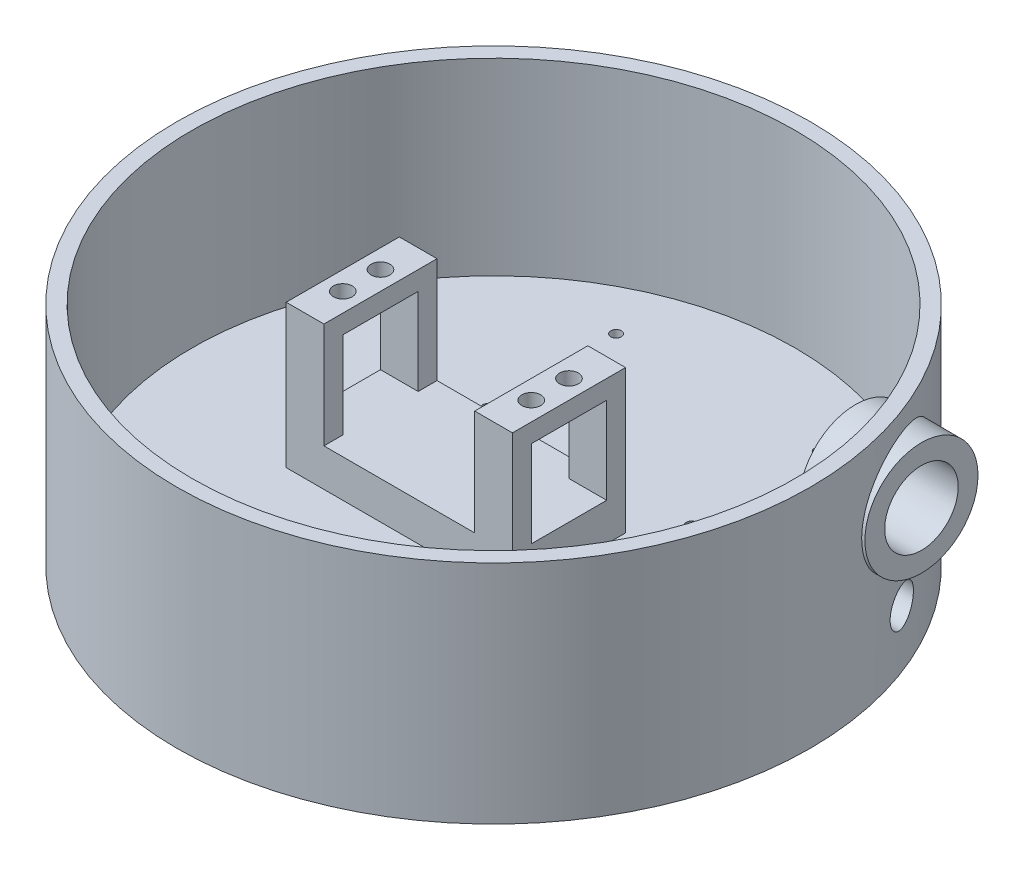
from build123d import *

# Parameters (mm, degrees)
SKETCH1_R                   = 84
BASE_DEPTH                  = 10
SKETCH2_R                   = 84
SKETCH2_R_2                 = 80
WALLS_DEPTH                 = 50
SKETCH3_W                   = 10.006475694
SKETCH3_H                   = 5
MOTOR_MOUNT_1_DEPTH         = 38
SKETCH3_5_W                 = 10
SKETCH3_5_H                 = 5
MOTOR_MOUNT_2_DEPTH         = 38
SKETCH6_W                   = 10.006475694
SKETCH6_H                   = 20
SKETCH6_R                   = 2.5
SKETCH6_W_2                 = 10
MOTOR_SCREW_HOLES_DEPTH     = 5
SKETCH7_R                   = 1.4
PERFBOARD_SCREW_HOLES_DEPTH = 6
BOSS_EXTRUDE1_DEPTH         = 10
SKETCH10_R                  = 9.75
SKETCH10_R_2                = 5
CUT_EXTRUDE1_DEPTH          = 134.086438077
BOSS_EXTRUDE2_START         = 66
SKETCH10_3_R                = 15
SKETCH10_3_R_2              = 9.75
BOSS_EXTRUDE2_DEPTH         = 17.5


with BuildPart() as part:
    # Sketch1 → base (new body)
    with BuildSketch(Plane(origin=(0, 0, 0), x_dir=(1, 0, 0), z_dir=(0, 1, 0))):
        Circle(SKETCH1_R)
    extrude(amount=BASE_DEPTH)

    # Sketch2 → walls (add)
    with BuildSketch(Plane(origin=(0, 10, 0), x_dir=(1, 0, 0), z_dir=(0, 1, 0))):
        Circle(SKETCH2_R)
        Circle(SKETCH2_R_2, mode=Mode.SUBTRACT)
    extrude(amount=WALLS_DEPTH)

    # Sketch3 → motor mount 1 (add)
    with BuildSketch(Plane(origin=(0, 10, 0), x_dir=(1, 0, 0), z_dir=(0, 1, 0))):
        with Locations((15.003237847, -12.5)):
            Rectangle(SKETCH3_W, SKETCH3_H)
        with Locations((15.003237847, 12.5)):
            Rectangle(SKETCH3_W, SKETCH3_H)
    extrude(amount=MOTOR_MOUNT_1_DEPTH)

    # Sketch3_5 → motor mount 2 (add)
    with BuildSketch(Plane(origin=(0, 10, 0), x_dir=(1, 0, 0), z_dir=(0, 1, 0))):
        with Locations((-35, -12.5)):
            Rectangle(SKETCH3_5_W, SKETCH3_5_H)
        with Locations((-35, 12.5)):
            Rectangle(SKETCH3_5_W, SKETCH3_5_H)
    extrude(amount=MOTOR_MOUNT_2_DEPTH)

    # Sketch6 → motor screw holes (add)
    # profile 1 of 2: a face of its own
    with BuildSketch(Plane(origin=(0, 48, 0), x_dir=(1, 0, 0), z_dir=(0, 1, 0))):
        with Locations((15.003237847, 0)):
            Rectangle(SKETCH6_W, SKETCH6_H)
        with Locations((15, 5)):
            Circle(SKETCH6_R, mode=Mode.SUBTRACT)
        with Locations((15, -5)):
            Circle(SKETCH6_R, mode=Mode.SUBTRACT)
    # profile 2 of 2: a face of its own
    with BuildSketch(Plane(origin=(0, 48, 0), x_dir=(1, 0, 0), z_dir=(0, 1, 0))):
        with Locations((-35, 0)):
            Rectangle(SKETCH6_W_2, SKETCH6_H)
        with Locations((-35, 5)):
            Circle(SKETCH6_R, mode=Mode.SUBTRACT)
        with Locations((-35, -5)):
            Circle(SKETCH6_R, mode=Mode.SUBTRACT)
    extrude(amount=-MOTOR_SCREW_HOLES_DEPTH)

    # Sketch7 → perfboard screw holes (cut)
    with BuildSketch(Plane(origin=(0, 10, 0), x_dir=(1, 0, 0), z_dir=(0, 1, 0))):
        with Locations((-27, 59.5)):
            Circle(SKETCH7_R)
        with Locations((-27, 25.5)):
            Circle(SKETCH7_R)
        with Locations((27, 25.5)):
            Circle(SKETCH7_R)
        with Locations((27, 59.5)):
            Circle(SKETCH7_R)
    extrude(amount=-PERFBOARD_SCREW_HOLES_DEPTH, mode=Mode.SUBTRACT)

    # Sketch9 → Boss-Extrude1 (add)
    with BuildSketch(Plane(origin=(0, 10, 0), x_dir=(1, 0, 0), z_dir=(0, 1, 0))):
        Polygon((10, 15), (-30, 15), (-30, 10), (-40, 10), (-40, -10), (-30, -10), (-30, -15), (10, -15), (10, -10), (20.006475694, -10), (20.006475694, 10), (10, 10), align=None)
    extrude(amount=BOSS_EXTRUDE1_DEPTH)

    # Sketch10 → Cut-Extrude1 (cut, through all)
    with BuildSketch(Plane(origin=(0, 0, 0), x_dir=(0, 0, -1), z_dir=(1, 0, 0))):
        with Locations((30, 40)):
            Circle(SKETCH10_R)
        with Locations((30, 15)):
            Circle(SKETCH10_R_2)
    extrude(amount=CUT_EXTRUDE1_DEPTH, mode=Mode.SUBTRACT)

    # Sketch10_3 → Boss-Extrude2 (add)
    with BuildSketch(Plane(origin=(0, 0, 0), x_dir=(0, 0, -1), z_dir=(1, 0, 0)).offset(BOSS_EXTRUDE2_START)):
        with Locations((30, 40)):
            Circle(SKETCH10_3_R)
        with Locations((30, 40)):
            Circle(SKETCH10_3_R_2, mode=Mode.SUBTRACT)
    extrude(amount=BOSS_EXTRUDE2_DEPTH)


solid = part.part
